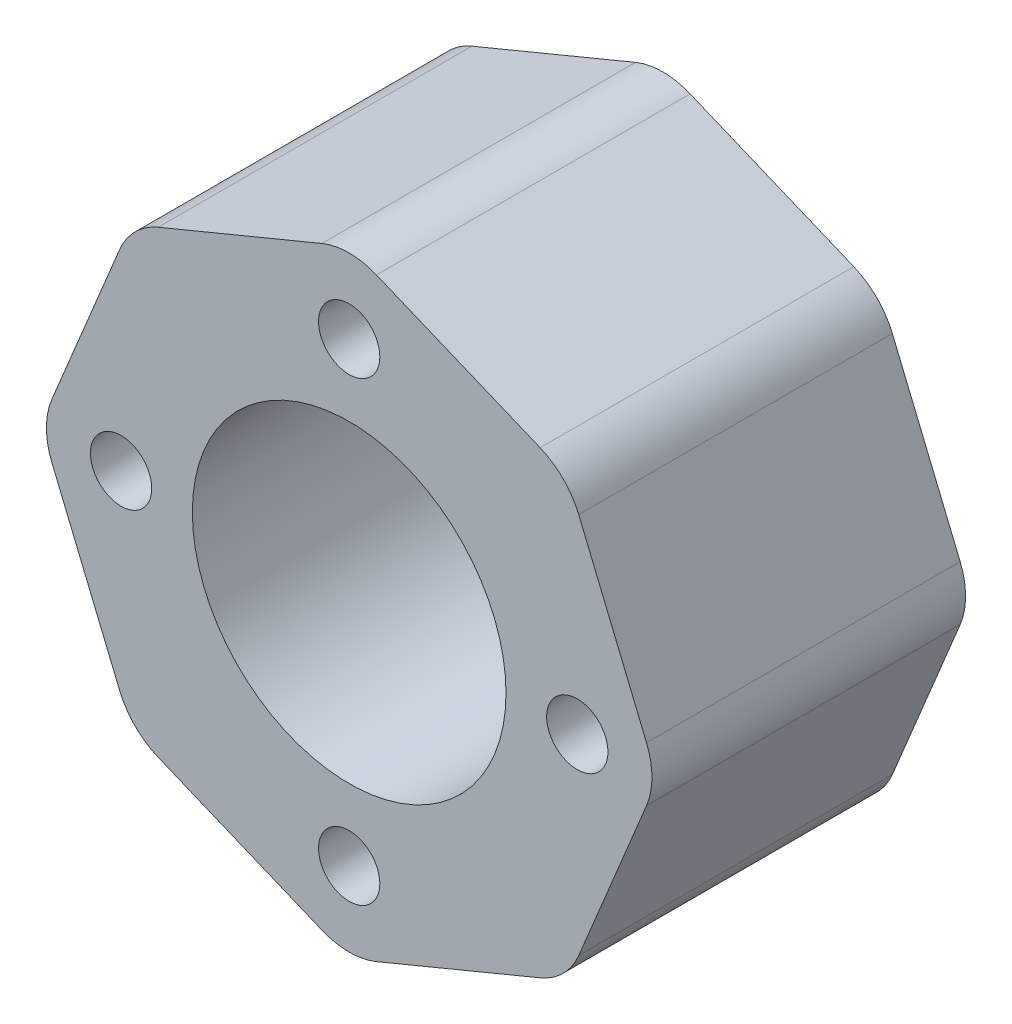
from build123d import *

# Parameters (mm, degrees)
BOSS_EXTRUDE1_DEPTH  = 22
FILLET1_R            = 5
M4_CLEARANCE_HOLE1_D = 4.3
SKETCH5_R            = 11
CUT_EXTRUDE1_DEPTH   = 22


with BuildPart() as part:
    # Sketch1 → Boss-Extrude1 (new body)
    with BuildSketch(Plane.XY):
        Polygon((0, -21.647844006), (15.307337295, -15.307337295), (21.647844006, 0), (15.307337295, 15.307337295), (0, 21.647844006), (-15.307337295, 15.307337295), (-21.647844006, 0), (-15.307337295, -15.307337295), align=None)
    extrude(amount=BOSS_EXTRUDE1_DEPTH)

    # Fillet1
    fillet1_edges = [part.edges().sort_by_distance(p)[0] for p in [
        (15.307337295, -15.307337295, 11),
        (0, -21.647844006, 11),
        (-15.307337295, -15.307337295, 11),
        (-21.647844006, 0, 11),
        (-15.307337295, 15.307337295, 11),
        (0, 21.647844006, 11),
        (15.307337295, 15.307337295, 11),
        (21.647844006, 0, 11),
    ]]
    fillet(fillet1_edges, radius=FILLET1_R)

    # M4 Clearance Hole1 (through all)
    with Locations(Plane.XY.offset(22)):
        with Locations((0, 16), (16, 0), (0, -16), (-16, 0)):
            Hole(M4_CLEARANCE_HOLE1_D / 2)

    # Sketch5 → Cut-Extrude1 (cut)
    with BuildSketch(Plane.XY.offset(22)):
        Circle(SKETCH5_R)
    extrude(amount=-CUT_EXTRUDE1_DEPTH, mode=Mode.SUBTRACT)


solid = part.part
